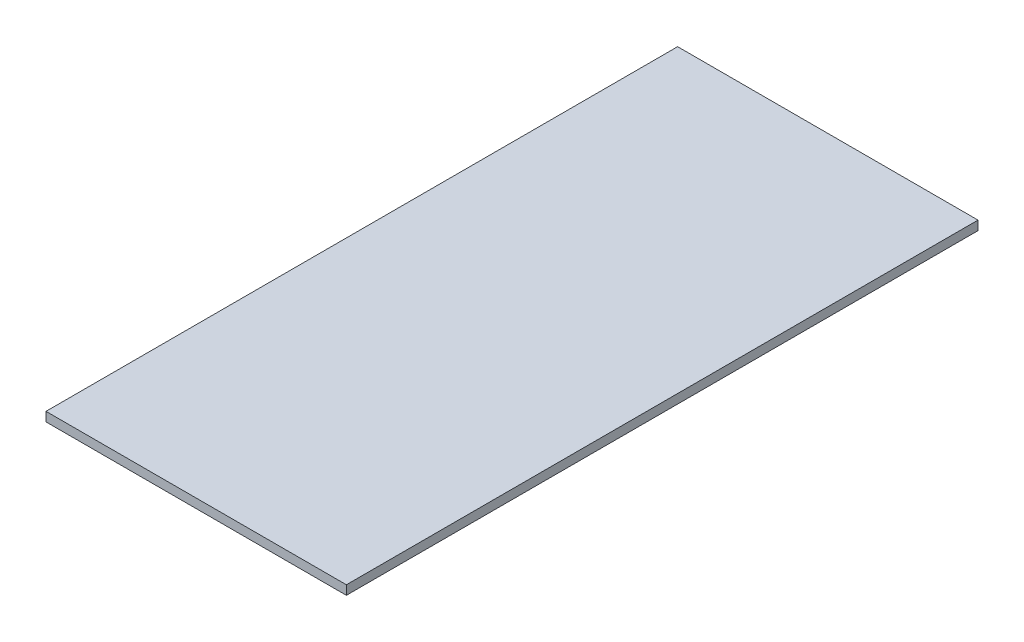
from build123d import *

# Parameters (mm, degrees)
SKETCH1_W           = 541.274
SKETCH1_H           = 1138.174
BOSS_EXTRUDE1_DEPTH = 16.51


with BuildPart() as part:
    # Sketch1 → Boss-Extrude1 (new body)
    with BuildSketch(Plane(origin=(0, 0, 0), x_dir=(1, 0, 0), z_dir=(0, 1, 0))):
        Rectangle(SKETCH1_W, SKETCH1_H)
    extrude(amount=BOSS_EXTRUDE1_DEPTH)


solid = part.part
